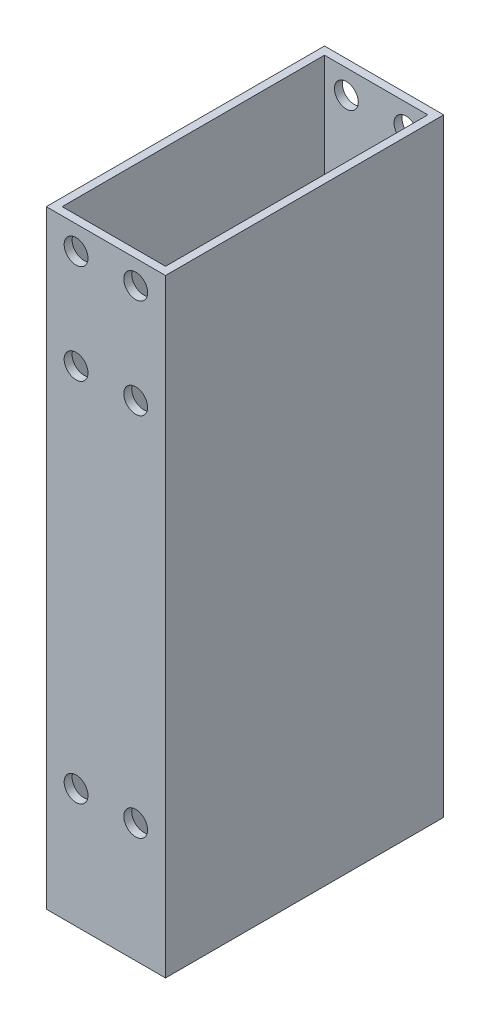
from build123d import *

# Parameters (mm, degrees)
SKETCH_1_W          = 30
SKETCH_1_H          = 766.14
SKETCH_1_R          = 2
SKETCH_1_R_2        = 1.999999998
EXTRUDE_2_DEPTH     = 70
SKETCH_2_W          = 26
SKETCH_2_H          = 66
CUT_EXTRUDE_3_DEPTH = 767.14
SKETCH_3_W          = 30
SKETCH_3_H          = 624.936750841
CUT_EXTRUDE_4_DEPTH = 71
SKETCH_4_R          = 3
CUT_EXTRUDE_5_DEPTH = 115


with BuildPart() as part:
    # 草图1 → 凸台-拉伸2 (new body)
    with BuildSketch(Plane.XY):
        Rectangle(SKETCH_1_W, SKETCH_1_H)
        with Locations((-7.500000035, 377.074776011)):
            Circle(SKETCH_1_R, mode=Mode.SUBTRACT)
        with Locations((7.499999965, 377.074776011)):
            Circle(SKETCH_1_R, mode=Mode.SUBTRACT)
        with Locations((-7.500000035, 352.074776011)):
            Circle(SKETCH_1_R, mode=Mode.SUBTRACT)
        with Locations((7.499999965, 352.074776011)):
            Circle(SKETCH_1_R, mode=Mode.SUBTRACT)
        with Locations((7.499878903, 260.000000008)):
            Circle(SKETCH_1_R_2, mode=Mode.SUBTRACT)
        with Locations((-7.500121097, 260.000000008)):
            Circle(SKETCH_1_R_2, mode=Mode.SUBTRACT)
    extrude(amount=EXTRUDE_2_DEPTH)

    # 草图2 → 切除-拉伸3 (cut, through all)
    with BuildSketch(Plane.XZ.offset(383.07)):
        with Locations((0, 35)):
            Rectangle(SKETCH_2_W, SKETCH_2_H)
    extrude(amount=-CUT_EXTRUDE_3_DEPTH, mode=Mode.SUBTRACT)

    # 草图3 → 切除-拉伸4 (cut, through all)
    with BuildSketch(Plane.XY.offset(70)):
        with Locations((0, -82.468375421)):
            Rectangle(SKETCH_3_W, SKETCH_3_H)
    extrude(amount=-CUT_EXTRUDE_4_DEPTH, mode=Mode.SUBTRACT)

    # 草图4 → 切除-拉伸5 (cut)
    with BuildSketch(Plane.XY.offset(70)):
        with Locations((-7.500000035, 377.074776011)):
            Circle(SKETCH_4_R)
        with Locations((7.499999965, 377.074776011)):
            Circle(SKETCH_4_R)
        with Locations((7.499999965, 352.074776011)):
            Circle(SKETCH_4_R)
        with Locations((-7.500000035, 352.074776011)):
            Circle(SKETCH_4_R)
        with Locations((-7.500121097, 260.000000008)):
            Circle(SKETCH_4_R)
        with Locations((7.499878903, 260.000000008)):
            Circle(SKETCH_4_R)
    extrude(amount=-CUT_EXTRUDE_5_DEPTH, mode=Mode.SUBTRACT)


solid = part.part
